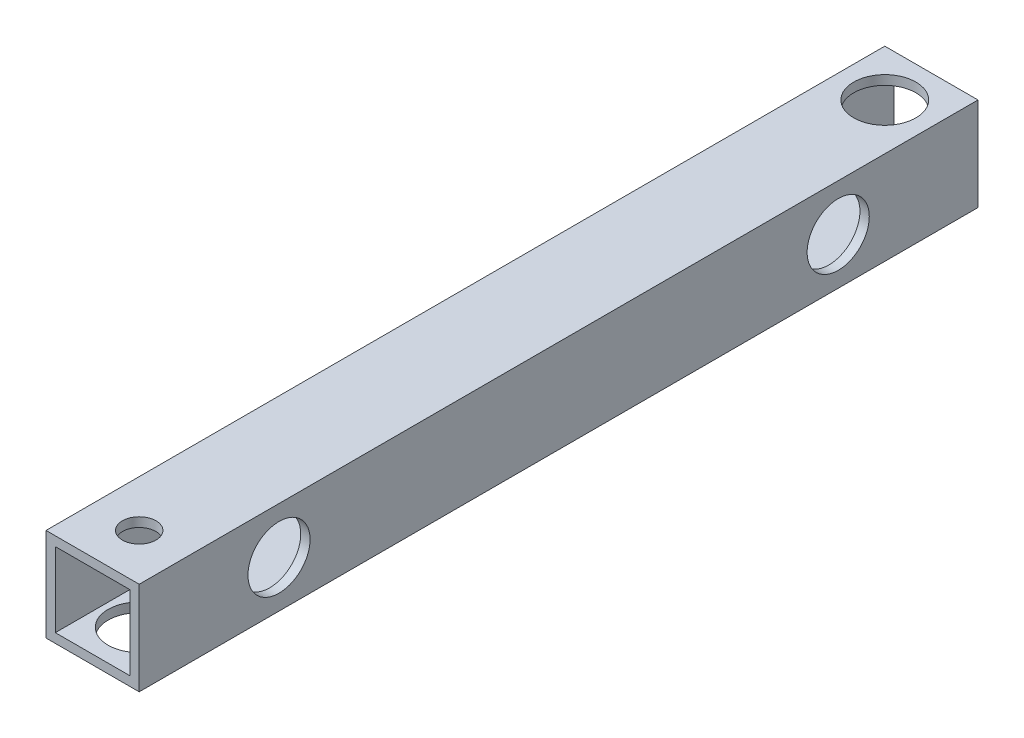
from build123d import *

# Parameters (mm, degrees)
SKETCH_1_W          = 15
SKETCH_1_H          = 15
SKETCH_1_W_2        = 12
SKETCH_1_H_2        = 12
EXTRUDE_1_DEPTH     = 135
SKETCH_2_R          = 2.7
CUT_EXTRUDE_1_DEPTH = 25
SKETCH_3_R          = 2.25
SKETCH_3_R_2        = 2.7
CUT_EXTRUDE_2_DEPTH = 25
SKETCH_4_R          = 5
CUT_EXTRUDE_3_DEPTH = 10
SKETCH_5_R          = 5
CUT_EXTRUDE_4_DEPTH = 10
SKETCH_6_R          = 5
CUT_EXTRUDE_5_DEPTH = 10


with BuildPart() as part:
    # ｽｹｯﾁ1 → ﾎﾞｽ - 押し出し1 (new body)
    with BuildSketch(Plane.XY):
        Rectangle(SKETCH_1_W, SKETCH_1_H)
        Rectangle(SKETCH_1_W_2, SKETCH_1_H_2, mode=Mode.SUBTRACT)
    extrude(amount=EXTRUDE_1_DEPTH)

    # ｽｹｯﾁ2 → ｶｯﾄ - 押し出し1 (cut)
    with BuildSketch(Plane(origin=(7.5, 0, 0), x_dir=(0, 0, -1), z_dir=(1, 0, 0))):
        with Locations((-112.5, 0)):
            Circle(SKETCH_2_R)
        with Locations((-22.5, 0)):
            Circle(SKETCH_2_R)
    extrude(amount=-CUT_EXTRUDE_1_DEPTH, mode=Mode.SUBTRACT)

    # ｽｹｯﾁ3 → ｶｯﾄ - 押し出し2 (cut)
    with BuildSketch(Plane(origin=(0, 7.5, 0), x_dir=(1, 0, 0), z_dir=(0, 1, 0))):
        with Locations((0, -7.5)):
            Circle(SKETCH_3_R)
        with Locations((0, -127.5)):
            Circle(SKETCH_3_R_2)
    extrude(amount=-CUT_EXTRUDE_2_DEPTH, mode=Mode.SUBTRACT)

    # ｽｹｯﾁ4 → ｶｯﾄ - 押し出し3 (cut)
    with BuildSketch(Plane(origin=(0, 7.5, 0), x_dir=(1, 0, 0), z_dir=(0, 1, 0))):
        with Locations((0, -7.5)):
            Circle(SKETCH_4_R)
    extrude(amount=-CUT_EXTRUDE_3_DEPTH, mode=Mode.SUBTRACT)

    # ｽｹｯﾁ5 → ｶｯﾄ - 押し出し4 (cut)
    with BuildSketch(Plane(origin=(7.5, 0, 0), x_dir=(0, 0, -1), z_dir=(1, 0, 0))):
        with Locations((-22.5, 0)):
            Circle(SKETCH_5_R)
        with Locations((-112.5, 0)):
            Circle(SKETCH_5_R)
    extrude(amount=-CUT_EXTRUDE_4_DEPTH, mode=Mode.SUBTRACT)

    # ｽｹｯﾁ6 → ｶｯﾄ - 押し出し5 (cut)
    with BuildSketch(Plane(origin=(0, -7.5, 0), x_dir=(-1, 0, 0), z_dir=(0, -1, 0))):
        with Locations((0, -127.5)):
            Circle(SKETCH_6_R)
    extrude(amount=-CUT_EXTRUDE_5_DEPTH, mode=Mode.SUBTRACT)


solid = part.part
